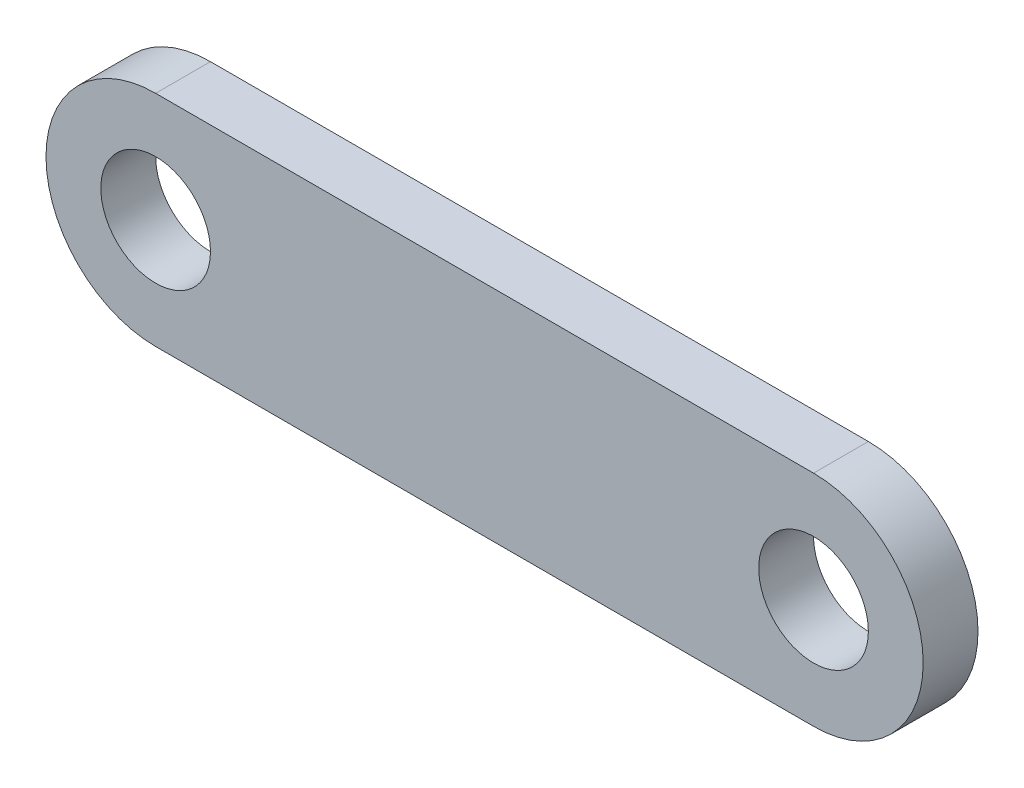
from build123d import *

# Parameters (mm, degrees)
SKETCH_1_R      = 5
EXTRUDE_1_DEPTH = 5


with BuildPart() as part:
    # Эскиз1 → Бобышка-Вытянуть1 (new body)
    with BuildSketch(Plane.XY):
        with BuildLine():
            Line((0, 10), (60, 10))
            ThreePointArc((60, 10), (70, 0), (60, -10))
            Line((60, -10), (0, -10))
            ThreePointArc((0, -10), (-10, 0), (0, 10))
        make_face()
        Circle(SKETCH_1_R, mode=Mode.SUBTRACT)
        with Locations((60, 0)):
            Circle(SKETCH_1_R, mode=Mode.SUBTRACT)
    extrude(amount=EXTRUDE_1_DEPTH)


solid = part.part
